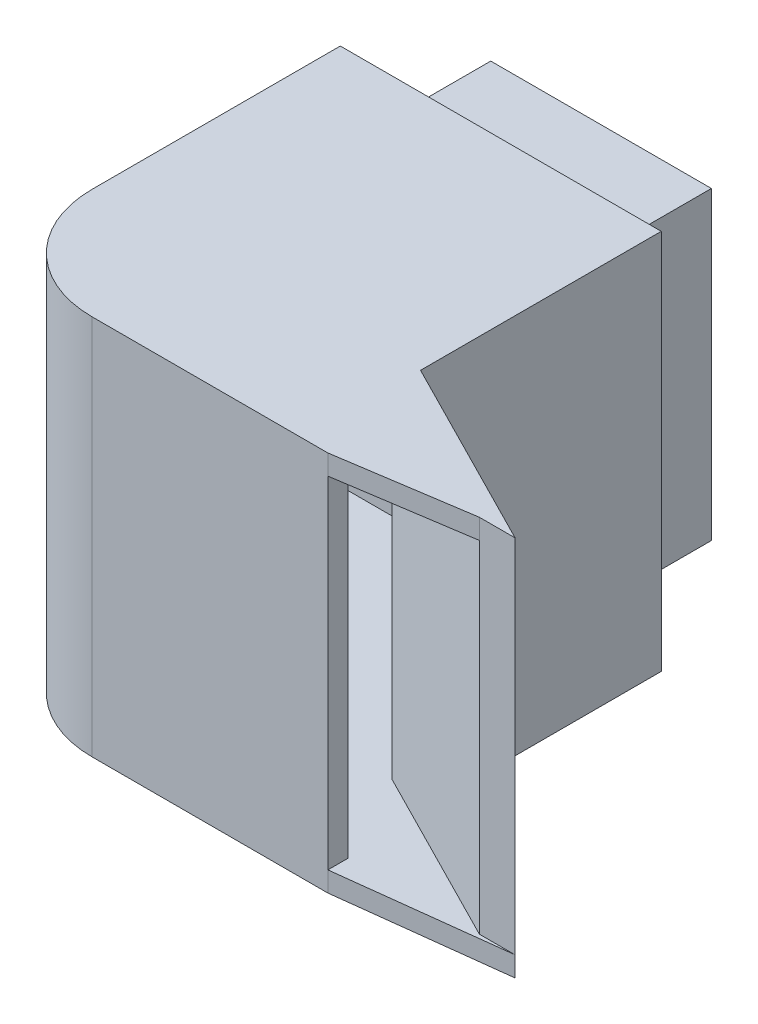
from build123d import *

# Parameters (mm, degrees)
BOSS_EXTRUDE1_DEPTH = 19
BOSS_EXTRUDE2_DEPTH = 1
BOSS_EXTRUDE3_DEPTH = 1
SKETCH4_W           = 11
SKETCH4_H           = 15.2
SKETCH4_W_2         = 9
SKETCH4_H_2         = 13.2
BOSS_EXTRUDE4_DEPTH = 5
SKETCH5_W           = 9
SKETCH5_H           = 13.2
CUT_EXTRUDE1_DEPTH  = 13


with BuildPart() as part:
    # Sketch1 → Boss-Extrude1 (new body)
    with BuildSketch(Plane(origin=(0, 0, 0), x_dir=(1, 0, 0), z_dir=(0, 1, 0))):
        with BuildLine():
            Line((-13.001443325, 4.911000499), (-13.001443325, -7.088999501))
            Line((-13.001443325, -7.088999501), (-3.408667462, -11.966682937))
            Line((-3.408667462, -11.966682937), (-5.189854063, -11.966682937))
            Line((-5.189854063, -11.966682937), (-14.067067881, -7.452844668))
            Line((-14.067067881, -7.452844668), (-14.067067881, 3.911000499))
            Line((-14.067067881, 3.911000499), (-28.001443325, 3.911000499))
            Line((-28.001443325, 3.911000499), (-28.001443325, -7.452844668))
            ThreePointArc((-28.001443325, -7.452844668), (-26.679370706, -10.644610317), (-23.487605056, -11.966682937))
            Line((-23.487605056, -11.966682937), (-11.742872705, -11.966682937))
            Line((-11.742872705, -11.966682937), (-11.742872705, -12.966682937))
            Line((-11.742872705, -12.966682937), (-23.494591297, -12.966682937))
            ThreePointArc((-23.494591297, -12.966682937), (-27.388523709, -11.353763321), (-29.001443325, -7.459830909))
            Line((-29.001443325, -7.459830909), (-29.001443325, 4.911000499))
            Line((-29.001443325, 4.911000499), (-13.001443325, 4.911000499))
        make_face()
    extrude(amount=BOSS_EXTRUDE1_DEPTH)

    # Sketch2 → Boss-Extrude2 (add)
    with BuildSketch(Plane(origin=(0, 19, 0), x_dir=(1, 0, 0), z_dir=(0, 1, 0))):
        with BuildLine():
            Line((-29.001443325, 4.911000499), (-13.001443325, 4.911000499))
            Line((-13.001443325, 4.911000499), (-13.001443325, -7.088999501))
            Line((-13.001443325, -7.088999501), (-3.408667462, -11.966682937))
            Line((-3.408667462, -11.966682937), (-5.189854063, -11.966682937))
            Line((-5.189854063, -11.966682937), (-11.742872705, -12.966682937))
            Line((-11.742872705, -12.966682937), (-23.494591297, -12.966682937))
            ThreePointArc((-23.494591297, -12.966682937), (-27.388523709, -11.353763321), (-29.001443325, -7.459830909))
            Line((-29.001443325, -7.459830909), (-29.001443325, 4.911000499))
        make_face()
    extrude(amount=-BOSS_EXTRUDE2_DEPTH)

    # Sketch3 → Boss-Extrude3 (add)
    with BuildSketch(Plane(origin=(0, 0, 0), x_dir=(-1, 0, 0), z_dir=(0, -1, 0))):
        with BuildLine():
            Line((29.001443325, -7.459830909), (29.001443325, 4.911000499))
            Line((29.001443325, 4.911000499), (13.001443325, 4.911000499))
            Line((13.001443325, 4.911000499), (13.001443325, -7.088999501))
            Line((13.001443325, -7.088999501), (3.408667462, -11.966682937))
            Line((3.408667462, -11.966682937), (5.189854063, -11.966682937))
            Line((5.189854063, -11.966682937), (14.067067881, -7.452844668))
            Line((14.067067881, -7.452844668), (14.067067881, 3.911000499))
            Line((14.067067881, 3.911000499), (28.001443325, 3.911000499))
            Line((28.001443325, 3.911000499), (28.001443325, -7.452844668))
            ThreePointArc((28.001443325, -7.452844668), (26.679370706, -10.644610317), (23.487605056, -11.966682937))
            Line((23.487605056, -11.966682937), (11.742872705, -11.966682937))
            Line((11.742872705, -11.966682937), (11.742872705, -12.966682937))
            Line((11.742872705, -12.966682937), (23.494591297, -12.966682937))
            ThreePointArc((23.494591297, -12.966682937), (27.388523709, -11.353763321), (29.001443325, -7.459830909))
        make_face()
        with BuildLine():
            Line((11.742872705, -12.966682937), (3.408667462, -11.966682937))
            Line((3.408667462, -11.966682937), (5.189854063, -11.966682937))
            Line((5.189854063, -11.966682937), (14.067067881, -7.452844668))
            Line((14.067067881, -7.452844668), (14.067067881, 3.911000499))
            Line((14.067067881, 3.911000499), (28.001443325, 3.911000499))
            Line((28.001443325, 3.911000499), (28.001443325, -7.452844668))
            ThreePointArc((28.001443325, -7.452844668), (26.679370706, -10.644610317), (23.487605056, -11.966682937))
            Line((23.487605056, -11.966682937), (11.742872705, -11.966682937))
            Line((11.742872705, -11.966682937), (11.742872705, -12.966682937))
        make_face()
    extrude(amount=-BOSS_EXTRUDE3_DEPTH)

    # Sketch4 → Boss-Extrude4 (add)
    with BuildSketch(Plane(origin=(0, 0, -4.911000499), x_dir=(-1, 0, 0), z_dir=(0, 0, -1))):
        with Locations((21.001443325, 9.5)):
            Rectangle(SKETCH4_W, SKETCH4_H)
        with Locations((21.001443325, 9.5)):
            Rectangle(SKETCH4_W_2, SKETCH4_H_2, mode=Mode.SUBTRACT)
    extrude(amount=BOSS_EXTRUDE4_DEPTH)

    # Sketch5 → Cut-Extrude1 (cut)
    with BuildSketch(Plane(origin=(0, 0, -9.911000499), x_dir=(-1, 0, 0), z_dir=(0, 0, -1))):
        with Locations((21.001443325, 9.5)):
            Rectangle(SKETCH5_W, SKETCH5_H)
    extrude(amount=-CUT_EXTRUDE1_DEPTH, mode=Mode.SUBTRACT)


solid = part.part
